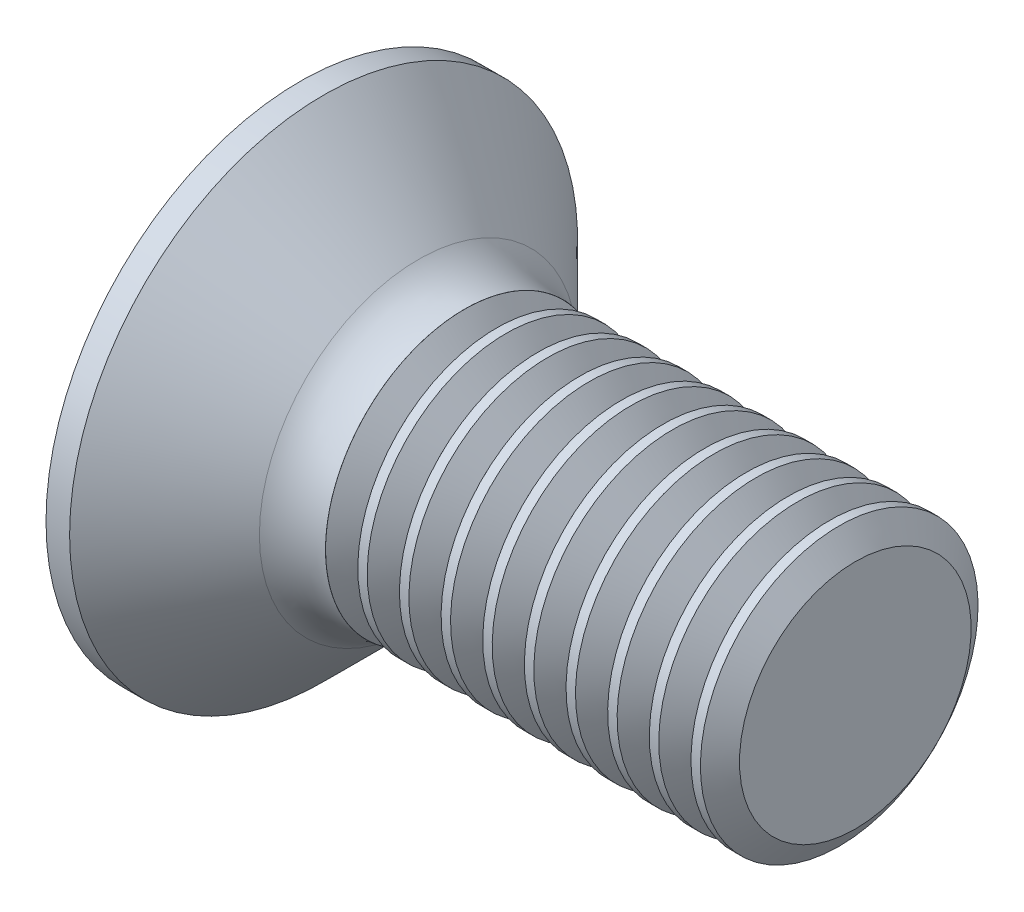
from build123d import *

# Parameters (mm, degrees)
FILLET1_R       = 2.5
SKETCH3_W       = 2.16
SKETCH3_H       = 9.8
SKETCH4_W       = 2.16
SKETCH4_H       = 4.175999656
RECPAT_COUNT    = 2
RECPAT_ANGLE    = 90
THDSCHPAT_COUNT = 10
THDSCHPAT_PITCH = 1.5


with BuildPart() as part:
    # BodySke → Base-Revolve (revolve)
    with BuildSketch(Plane.XY):
        Polygon((0, 0), (0, 9.15), (0.85, 9.15), (5, 5), (20, 5), (20, 0), align=None)
    revolve(axis=Axis((-6.35, 0, 0), (1, 0, 0)))

    # Fillet1
    fillet1_edges = [part.edges().sort_by_distance(p)[0] for p in [
        (5, -5, 0),
    ]]
    fillet(fillet1_edges, radius=FILLET1_R)

    # Sketch3 → Recess section 0
    with BuildSketch(Plane.ZY):
        Rectangle(SKETCH3_W, SKETCH3_H)
    # Sketch4 → Recess section 1
    with BuildSketch(Plane.ZY.offset(-5.64)):
        Rectangle(SKETCH4_W, SKETCH4_H)
    recess = loft(mode=Mode.SUBTRACT)

    # RecPat: Recess ×2 about axis
    recpat_axis = Axis((0, 0, 0), (1, 0, 0))
    for i in range(1, RECPAT_COUNT):
        add(recess.rotate(recpat_axis, i * RECPAT_ANGLE / (RECPAT_COUNT - 1)), mode=Mode.SUBTRACT)

    # RecCorSke → RecessCore (revolve, cut)
    with BuildSketch(Plane.XY):
        Polygon((0, 0), (0, 2.324887219), (5.64, 1.9305), (6.267257474, 0), align=None)
    revolve(axis=Axis((-3.175, 0, 0), (1, 0, 0)), mode=Mode.SUBTRACT)

    # ThdSchSke → ThreadSchematic (revolve, cut)
    with BuildSketch(Plane.XY):
        Polygon((6.500001, -4.172), (5.920229158, -5), (5.920229158, -6.25), (7.079772842, -6.25), (7.079772842, -5), align=None)
    threadschematic = revolve(axis=Axis((-3.175, 0, 0), (1, 0, 0)), mode=Mode.SUBTRACT)

    # ThdSchPat: ThreadSchematic ×10
    with Locations(*[(i * THDSCHPAT_PITCH, 0, 0) for i in range(1, THDSCHPAT_COUNT)]):
        add(threadschematic, mode=Mode.SUBTRACT)


solid = part.part
